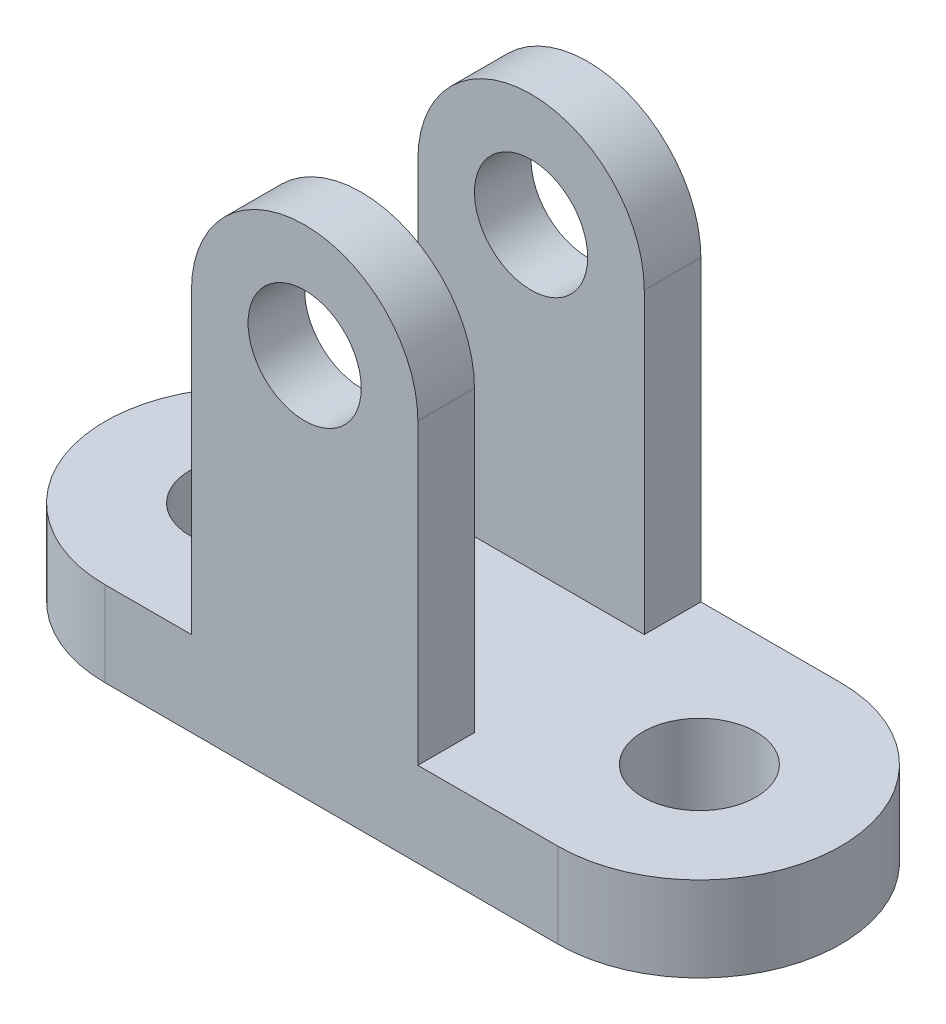
from build123d import *

# Parameters (mm, degrees)
SKETCH2_R           = 10
BOSS_EXTRUDE1_DEPTH = 15
SKETCH4_R           = 10
BOSS_EXTRUDE2_DEPTH = 50
SKETCH5_W           = 30
SKETCH5_H           = 72.699493752
CUT_EXTRUDE1_DEPTH  = 25


with BuildPart() as part:
    # Sketch2 → Boss-Extrude1 (new body)
    with BuildSketch(Plane(origin=(0, 0, 0), x_dir=(1, 0, 0), z_dir=(0, 1, 0))):
        with BuildLine():
            Line((-35.258358851, 25), (44.741641149, 25))
            ThreePointArc((44.741641149, 25), (69.741641149, 0), (44.741641149, -25))
            Line((44.741641149, -25), (-35.258358851, -25))
            ThreePointArc((-35.258358851, -25), (-60.258358851, 0), (-35.258358851, 25))
        make_face()
        with Locations((-35.258358851, 0)):
            Circle(SKETCH2_R, mode=Mode.SUBTRACT)
        with Locations((44.741641149, 0)):
            Circle(SKETCH2_R, mode=Mode.SUBTRACT)
    extrude(amount=BOSS_EXTRUDE1_DEPTH)

    # Sketch4 → Boss-Extrude2 (add)
    with BuildSketch(Plane.XY.offset(25)):
        with BuildLine():
            Line((-20, 67.699493752), (-20, 15))
            Line((-20, 15), (20, 15))
            Line((20, 15), (20, 67.699493752))
            ThreePointArc((20, 67.699493752), (0, 87.699493752), (-20, 67.699493752))
        make_face()
        with Locations((0, 67.699493752)):
            Circle(SKETCH4_R, mode=Mode.SUBTRACT)
    extrude(amount=-BOSS_EXTRUDE2_DEPTH)

    # Sketch5 → Cut-Extrude1 (cut, symmetric)
    with BuildSketch(Plane(origin=(0, 0, 0), x_dir=(0, 0, -1), z_dir=(1, 0, 0))):
        with Locations((0, 51.349746876)):
            Rectangle(SKETCH5_W, SKETCH5_H)
    extrude(amount=CUT_EXTRUDE1_DEPTH, both=True, mode=Mode.SUBTRACT)


solid = part.part
